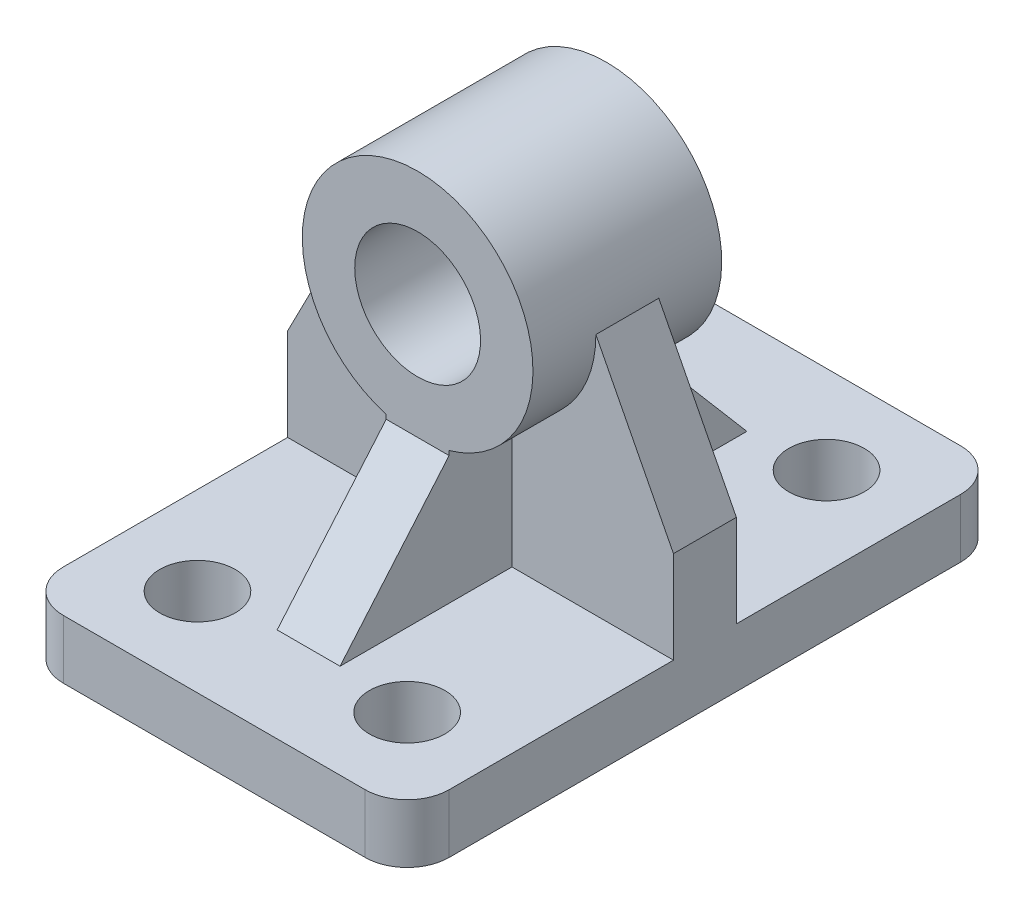
from build123d import *

# Parameters (mm, degrees)
CROQUIS1_W              = 92
CROQUIS1_H              = 142
CROQUIS1_R              = 9
SALIENTE_EXTRUIR1_DEPTH = 100
CROQUIS2_R              = 15
CORTAR_EXTRUIR1_DEPTH   = 142
CORTAR_EXTRUIR2_DEPTH   = 92
CORTAR_EXTRUIR3_DEPTH   = 63.5
CORTAR_EXTRUIR4_DEPTH   = 63.5
REDONDEO1_R             = 10


with BuildPart() as part:
    # Croquis1 → Saliente-Extruir1 (new body)
    with BuildSketch(Plane(origin=(0, 0, 0), x_dir=(1, 0, 0), z_dir=(0, 1, 0))):
        with Locations((-65.401360544, 14.360544218)):
            Rectangle(CROQUIS1_W, CROQUIS1_H)
        with Locations((-90.401360544, 64.360544218)):
            Circle(CROQUIS1_R, mode=Mode.SUBTRACT)
        with Locations((-90.401360544, -35.639455782)):
            Circle(CROQUIS1_R, mode=Mode.SUBTRACT)
        with Locations((-40.401360544, 64.360544218)):
            Circle(CROQUIS1_R, mode=Mode.SUBTRACT)
        with Locations((-40.401360544, -35.639455782)):
            Circle(CROQUIS1_R, mode=Mode.SUBTRACT)
    extrude(amount=SALIENTE_EXTRUIR1_DEPTH)

    # Croquis2 → Cortar-Extruir1 (cut)
    with BuildSketch(Plane.XY.offset(56.639455782)):
        with BuildLine():
            Line((-111.401360544, 36), (-92.901360544, 72))
            ThreePointArc((-92.901360544, 72), (-65.401360544, 99.5), (-37.901360544, 72))
            Line((-37.901360544, 72), (-19.401360544, 36))
            Line((-19.401360544, 36), (-19.401360544, 100))
            Line((-19.401360544, 100), (-111.401360544, 100))
            Line((-111.401360544, 100), (-111.401360544, 36))
        make_face()
        with Locations((-65.401360544, 72)):
            Circle(CROQUIS2_R)
    extrude(amount=-CORTAR_EXTRUIR1_DEPTH, mode=Mode.SUBTRACT)

    # Croquis3 → Cortar-Extruir2 (cut)
    with BuildSketch(Plane(origin=(-19.401360544, 0, 0), x_dir=(0, 0, -1), z_dir=(1, 0, 0))):
        Polygon((62.860544218, 14), (36.860544218, 44.5), (36.860544218, 99.5), (85.360544218, 99.5), (85.360544218, 14), align=None)
        Polygon((-56.639455782, 14), (-34.139455782, 14), (-8.139455782, 44.5), (-8.139455782, 99.5), (-56.639455782, 99.5), align=None)
    extrude(amount=-CORTAR_EXTRUIR2_DEPTH, mode=Mode.SUBTRACT)

    # Croquis4 → Cortar-Extruir3 (cut)
    with BuildSketch(Plane.XY.offset(56.639455782)):
        with BuildLine():
            Line((-92.901360544, 72), (-111.401360544, 36))
            Line((-111.401360544, 36), (-111.401360544, 14))
            Line((-111.401360544, 14), (-72.901360544, 14))
            Line((-72.901360544, 14), (-72.901360544, 45.542486889))
            ThreePointArc((-72.901360544, 45.542486889), (-87.338771513, 55.416876048), (-92.901360544, 72))
        make_face()
        with BuildLine():
            Line((-19.401360544, 36), (-37.901360544, 72))
            ThreePointArc((-37.901360544, 72), (-43.463949576, 55.416876048), (-57.901360544, 45.542486889))
            Line((-57.901360544, 45.542486889), (-57.901360544, 14))
            Line((-57.901360544, 14), (-19.401360544, 14))
            Line((-19.401360544, 14), (-19.401360544, 36))
        make_face()
    extrude(amount=-CORTAR_EXTRUIR3_DEPTH, mode=Mode.SUBTRACT)

    # Croquis7 → Cortar-Extruir4 (cut)
    with BuildSketch(Plane(origin=(0, 0, -85.360544218), x_dir=(-1, 0, 0), z_dir=(0, 0, -1))):
        with BuildLine():
            Line((57.901360544, 14), (57.901360544, 45.542486889))
            ThreePointArc((57.901360544, 45.542486889), (43.463949576, 55.416876048), (37.901360544, 72))
            Line((37.901360544, 72), (19.401360544, 36))
            Line((19.401360544, 36), (19.401360544, 14))
            Line((19.401360544, 14), (57.901360544, 14))
        make_face()
        with BuildLine():
            ThreePointArc((92.901360544, 72), (87.338771513, 55.416876048), (72.901360544, 45.542486889))
            Line((72.901360544, 45.542486889), (72.901360544, 14))
            Line((72.901360544, 14), (111.401360544, 14))
            Line((111.401360544, 14), (111.401360544, 36))
            Line((111.401360544, 36), (92.901360544, 72))
        make_face()
    extrude(amount=-CORTAR_EXTRUIR4_DEPTH, mode=Mode.SUBTRACT)

    # Redondeo1
    redondeo1_edges = [part.edges().sort_by_distance(p)[0] for p in [
        (-19.401360544, 7, -85.360544218),
        (-111.401360544, 7, -85.360544218),
        (-19.401360544, 7, 56.639455782),
        (-111.401360544, 7, 56.639455782),
    ]]
    fillet(redondeo1_edges, radius=REDONDEO1_R)


solid = part.part
